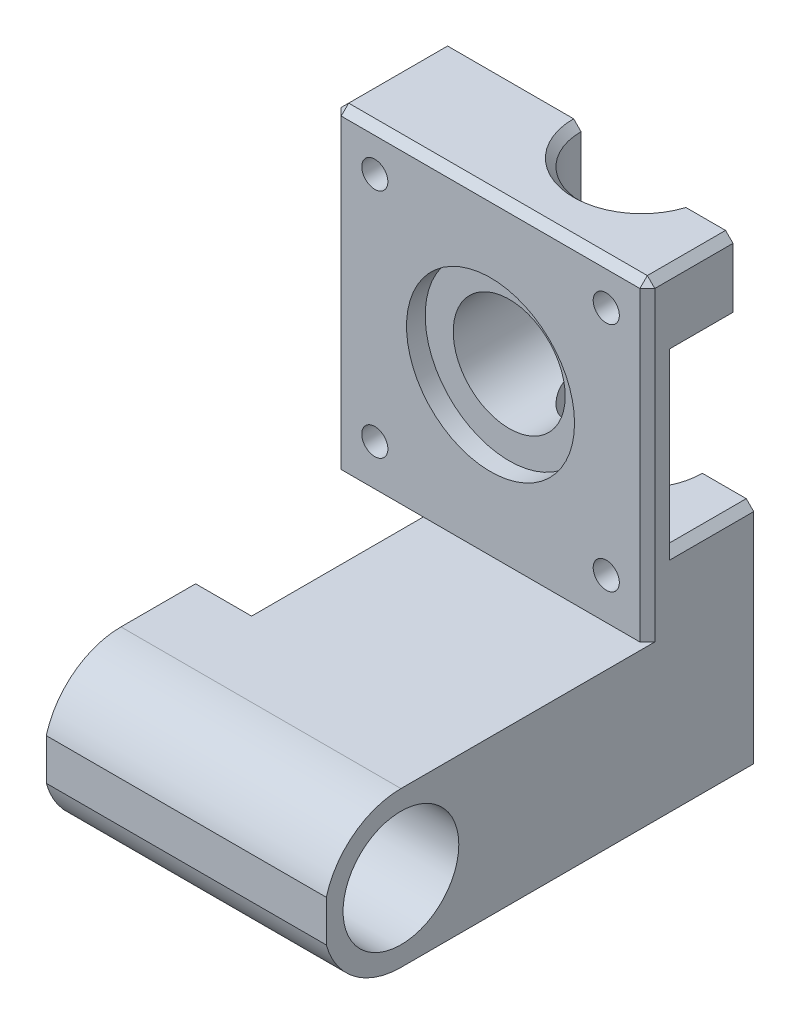
from build123d import *

# Parameters (mm, degrees)
BOSS_EXTRUDE1_DEPTH = 21
BOSS_EXTRUDE2_DEPTH = 5.75
BOSS_EXTRUDE3_DEPTH = 7
SKETCH6_W           = 14.25
SKETCH6_H           = 13
BOSS_EXTRUDE4_DEPTH = 12
BOSS_EXTRUDE5_DEPTH = 29
SKETCH8_R           = 11.25
CUT_EXTRUDE1_DEPTH  = 2.5
SKETCH9_R           = 1.75
SKETCH9_R_2         = 7.5
CUT_EXTRUDE2_DEPTH  = 15.25
SKETCH10_W          = 30
SKETCH10_H          = 20.75
BOSS_EXTRUDE6_DEPTH = 23
CUT_EXTRUDE4_DEPTH  = 15
SKETCH12_W          = 37.5
SKETCH12_H          = 20.75
BOSS_EXTRUDE7_DEPTH = 20
SKETCH13_R          = 7.75
CUT_EXTRUDE5_DEPTH  = 43
SKETCH14_R          = 1.5
CUT_EXTRUDE6_DEPTH  = 10
CHAMFER1_SIZE       = 1


with BuildPart() as part:
    # Sketch1 → Boss-Extrude1 (new body)
    with BuildSketch(Plane(origin=(0, 0, 0), x_dir=(1, 0, 0), z_dir=(0, 1, 0))):
        with BuildLine():
            Line((23.125, 14.25), (30, 14.25))
            Line((30, 14.25), (30, 0))
            Line((30, 0), (0, 0))
            Line((0, 0), (0, 14.25))
            Line((0, 14.25), (6.875, 14.25))
            ThreePointArc((6.875, 14.25), (15, 6.125), (23.125, 14.25))
        make_face()
    extrude(amount=BOSS_EXTRUDE1_DEPTH)

    # Sketch2 → Boss-Extrude2 (add)
    with BuildSketch(Plane.XZ):
        with BuildLine():
            Line((21.25, -14.25), (30, -14.25))
            Line((30, -14.25), (30, 0))
            Line((30, 0), (0, 0))
            Line((0, 0), (0, -14.25))
            Line((0, -14.25), (8.75, -14.25))
            ThreePointArc((8.75, -14.25), (15, -8), (21.25, -14.25))
        make_face()
    extrude(amount=BOSS_EXTRUDE2_DEPTH)

    # Sketch3 → Boss-Extrude3 (add)
    with BuildSketch(Plane.XZ.offset(5.75)):
        with BuildLine():
            Line((23.25, -14.25), (30, -14.25))
            Line((30, -14.25), (30, 0))
            Line((30, 0), (0, 0))
            Line((0, 0), (0, -14.25))
            Line((0, -14.25), (6.75, -14.25))
            ThreePointArc((6.75, -14.25), (15, -6), (23.25, -14.25))
        make_face()
    extrude(amount=BOSS_EXTRUDE3_DEPTH)

    # Sketch6 → Boss-Extrude4 (add)
    with BuildSketch(Plane.ZY):
        with Locations((-7.125, 14.5)):
            Rectangle(SKETCH6_W, SKETCH6_H)
    extrude(amount=BOSS_EXTRUDE4_DEPTH)

    # Sketch7 → Boss-Extrude5 (add)
    with BuildSketch(Plane(origin=(0, 21, 0), x_dir=(1, 0, 0), z_dir=(0, 1, 0))):
        with BuildLine():
            Line((-12, 0), (30, 0))
            Line((30, 0), (30, 5.621629424))
            Line((30, 5.621629424), (30, 11.47775747))
            Line((30, 11.47775747), (24.530058266, 11.47775747))
            Line((24.530058266, 11.47775747), (22.637427339, 11.47775747))
            ThreePointArc((22.637427339, 11.47775747), (13.592603845, 6.24782148), (6.875, 14.25))
            Line((6.875, 14.25), (0.717619185, 14.25))
            Line((0.717619185, 14.25), (-12, 14.25))
            Line((-12, 14.25), (-12, 5.621629424))
            Line((-12, 5.621629424), (-12, 0))
        make_face()
    extrude(amount=BOSS_EXTRUDE5_DEPTH)

    # Sketch8 → Cut-Extrude1 (cut)
    with BuildSketch(Plane.XY):
        with Locations((9, 29)):
            Circle(SKETCH8_R)
    extrude(amount=-CUT_EXTRUDE1_DEPTH, mode=Mode.SUBTRACT)

    # Sketch9 → Cut-Extrude2 (cut, through all)
    with BuildSketch(Plane.XY):
        with Locations((-6.5, 44.5)):
            Circle(SKETCH9_R)
        with Locations((-6.5, 13.5)):
            Circle(SKETCH9_R)
        with Locations((24.5, 13.5)):
            Circle(SKETCH9_R)
        with Locations((24.5, 44.5)):
            Circle(SKETCH9_R)
        with Locations((9, 29)):
            Circle(SKETCH9_R_2)
    extrude(amount=-CUT_EXTRUDE2_DEPTH, mode=Mode.SUBTRACT)

    # Sketch10 → Boss-Extrude6 (add)
    with BuildSketch(Plane.XY):
        with Locations((15, -2.375)):
            Rectangle(SKETCH10_W, SKETCH10_H)
    extrude(amount=BOSS_EXTRUDE6_DEPTH)

    # Sketch11 → Cut-Extrude4 (cut)
    with BuildSketch(Plane(origin=(30, 0, 0), x_dir=(0, 0, -1), z_dir=(1, 0, 0))):
        Polygon((11.47775747, 17.5), (4, 17.5), (4, 40), (11.47775747, 40), (11.47775747, 21), (14.25, 21), (14.25, 17.5), align=None)
    extrude(amount=-CUT_EXTRUDE4_DEPTH, mode=Mode.SUBTRACT)

    # Sketch12 → Boss-Extrude7 (add)
    with BuildSketch(Plane.XY.offset(23)):
        with Locations((11.25, -2.375)):
            Rectangle(SKETCH12_W, SKETCH12_H)
    extrude(amount=BOSS_EXTRUDE7_DEPTH)

    # Sketch13 → Cut-Extrude5 (cut, through all)
    with BuildSketch(Plane(origin=(30, 0, 0), x_dir=(0, 0, -1), z_dir=(1, 0, 0))):
        with BuildLine():
            ThreePointArc((-43, 0.389168048), (-39.283405983, 5.880872713), (-33, 8))
            Line((-33, 8), (-43, 8))
            Line((-43, 8), (-43, 0.389168048))
        make_face()
        with BuildLine():
            ThreePointArc((-33, -12.75), (-39.283405983, -10.630872713), (-43, -5.139168048))
            Line((-43, -5.139168048), (-43, -12.75))
            Line((-43, -12.75), (-33, -12.75))
        make_face()
        with Locations((-33, -2.375)):
            Circle(SKETCH13_R)
    extrude(amount=-CUT_EXTRUDE5_DEPTH, mode=Mode.SUBTRACT)

    # Sketch14 → Cut-Extrude6 (cut)
    with BuildSketch(Plane(origin=(0, -12.75, 0), x_dir=(-1, 0, 0), z_dir=(0, -1, 0))):
        with Locations((-20.625, -15)):
            Circle(SKETCH14_R)
        with Locations((-1.875, -15)):
            Circle(SKETCH14_R)
    extrude(amount=-CUT_EXTRUDE6_DEPTH, mode=Mode.SUBTRACT)

    # Chamfer1
    chamfer1_edges = [part.edges().sort_by_distance(p)[0] for p in [
        (30, 29, 0),
        (30, 17.5, -9.125),
        (30, 40, -7.738878735),
        (30, 28.75, -4),
        (-12, 29, 0),
        (-12, 8, -7.125),
        (-12, 50, -7.125),
        (13.592603845, 50, -6.24782148),
        (30, 50, -5.738878735),
        (9, 50, 0),
    ]]
    chamfer(chamfer1_edges, length=CHAMFER1_SIZE)


solid = part.part
